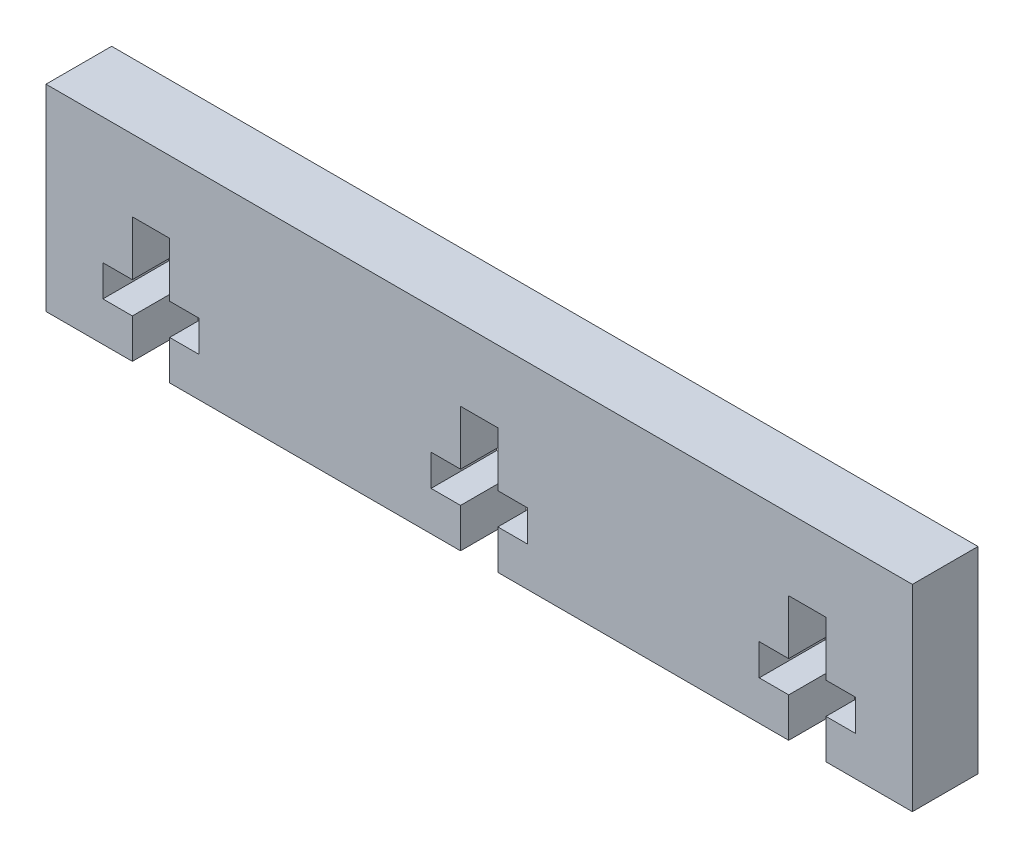
from build123d import *

# Parameters (mm, degrees)
BOSS_EXTRUDE1_DEPTH = 5


with BuildPart() as part:
    # Sketch1 → Boss-Extrude1 (new body)
    with BuildSketch(Plane.XY):
        Polygon((0, 0), (6.58, 0), (6.58, 3), (4.335, 3), (4.335, 5.39), (6.58, 5.39), (6.58, 9.54), (9.42, 9.54), (9.42, 5.39), (11.665, 5.39), (11.665, 3), (9.42, 3), (9.42, 0), (31.58, 0), (31.58, 3), (29.335, 3), (29.335, 5.39), (31.58, 5.39), (31.58, 9.54), (34.42, 9.54), (34.42, 5.39), (36.665, 5.39), (36.665, 3), (34.42, 3), (34.42, 0), (56.58, 0), (56.58, 3), (54.335, 3), (54.335, 5.39), (56.58, 5.39), (56.58, 9.54), (59.42, 9.54), (59.42, 5.39), (61.665, 5.39), (61.665, 3), (59.42, 3), (59.42, 0), (66, 0), (66, 15), (0, 15), align=None)
    extrude(amount=BOSS_EXTRUDE1_DEPTH)


solid = part.part
